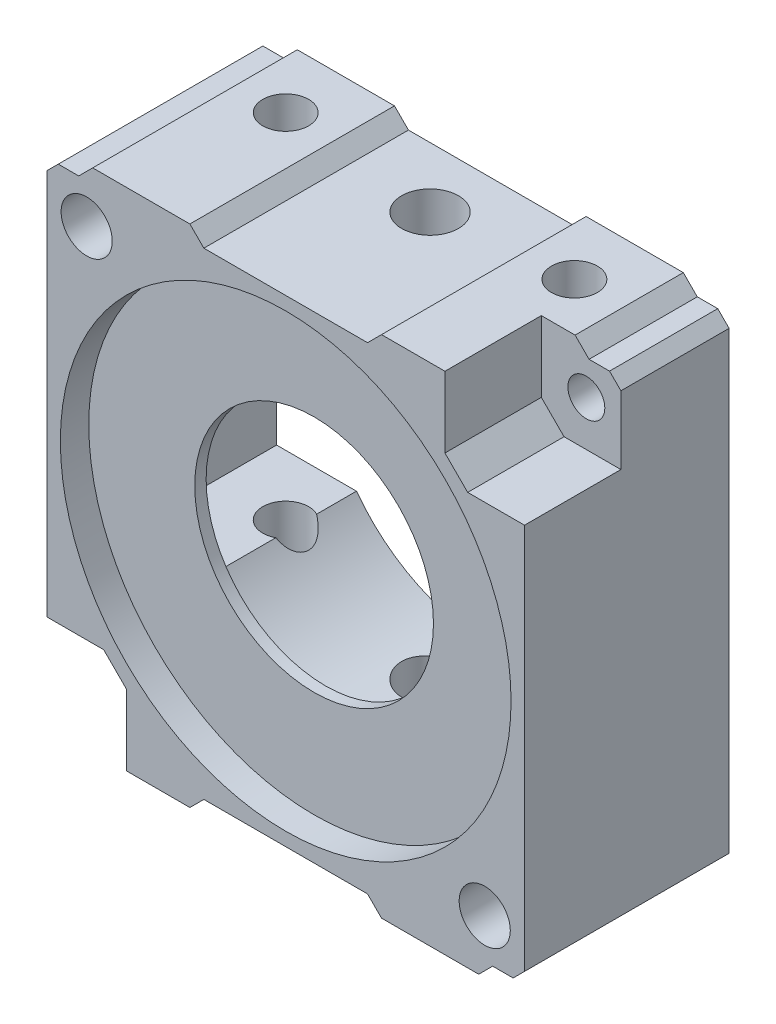
from build123d import *

# Parameters (mm, degrees)
BOSS_EXTRUDE2_DEPTH     = 18
SKETCH2_R               = 19.825
CUT_EXTRUDE1_DEPTH      = 2.5
SKETCH3_R               = 14.7
CUT_EXTRUDE2_DEPTH      = 14.5
CUT_EXTRUDE3_DEPTH      = 14.5
SKETCH5_R               = 10.5
CUT_EXTRUDE4_DEPTH      = 14.5
SKETCH7_R               = 2.5
SKETCH7_R_2             = 2.02
CUT_EXTRUDE6_DEPTH      = 30
CUT_EXTRUDE6_DEPTH_BACK = 60
SKETCH9_R               = 1.623885446
SKETCH9_R_2             = 2.25
CUT_EXTRUDE7_DEPTH      = 30
CUT_EXTRUDE8_DEPTH      = 8.48


with BuildPart() as part:
    # Sketch1 → Boss-Extrude2 (new body)
    with BuildSketch(Plane.XY):
        Polygon((-7.2, 21), (7.2, 21), (8.43, 22.23), (16.98, 22.23), (18.21, 21), (20.01, 21), (21.01, 20), (21.01, -20), (20.01, -21), (18.21, -21), (16.98, -22.23), (8.43, -22.23), (7.2, -21), (-7.2, -21), (-8.43, -22.23), (-16.98, -22.23), (-18.21, -21), (-20.01, -21), (-21.01, -20), (-21.01, 20), (-20.01, 21), (-18.21, 21), (-16.98, 22.23), (-8.43, 22.23), align=None)
    extrude(amount=BOSS_EXTRUDE2_DEPTH)

    # Sketch2 → Cut-Extrude1 (cut)
    with BuildSketch(Plane.XY.offset(18)):
        Circle(SKETCH2_R)
    extrude(amount=-CUT_EXTRUDE1_DEPTH, mode=Mode.SUBTRACT)

    # Sketch3 → Cut-Extrude2 (cut)
    with BuildSketch(Plane(origin=(0, 0, 0), x_dir=(-1, 0, 0), z_dir=(0, 0, -1))):
        Circle(SKETCH3_R)
    extrude(amount=-CUT_EXTRUDE2_DEPTH, mode=Mode.SUBTRACT)

    # Sketch4 → Cut-Extrude3 (cut)
    with BuildSketch(Plane(origin=(0, 0, 0), x_dir=(-1, 0, 0), z_dir=(0, 0, -1))):
        Polygon((18.8, 0), (18.8, 8.8), (-18.8, 8.8), (-18.8, -8.8), (18.8, -8.8), align=None)
    extrude(amount=-CUT_EXTRUDE3_DEPTH, mode=Mode.SUBTRACT)

    # Sketch5 → Cut-Extrude4 (cut)
    with BuildSketch(Plane(origin=(0, 0, 14.5), x_dir=(-1, 0, 0), z_dir=(0, 0, -1))):
        Circle(SKETCH5_R)
    extrude(amount=-CUT_EXTRUDE4_DEPTH, mode=Mode.SUBTRACT)

    # Sketch7 → Cut-Extrude6 (cut, two sides)
    with BuildSketch(Plane(origin=(0, 21, 0), x_dir=(1, 0, 0), z_dir=(0, 1, 0))) as cut_extrude6_sk:
        with Locations((0, -5.3)):
            Circle(SKETCH7_R)
        with Locations((12.7, -5.3)):
            Circle(SKETCH7_R_2)
        with Locations((-12.7, -5.3)):
            Circle(SKETCH7_R_2)
    extrude(amount=CUT_EXTRUDE6_DEPTH, mode=Mode.SUBTRACT)
    extrude(cut_extrude6_sk.sketch, amount=-CUT_EXTRUDE6_DEPTH_BACK, mode=Mode.SUBTRACT)

    # Sketch9 → Cut-Extrude7 (cut)
    with BuildSketch(Plane.XY.offset(18)):
        with Locations((17.97, 17.97)):
            Circle(SKETCH9_R)
        with Locations((-17.51, 17.505)):
            Circle(SKETCH9_R_2)
        with Locations((17.51, -17.505)):
            Circle(SKETCH9_R_2)
        with Locations((-17.97, -17.97)):
            Circle(SKETCH9_R)
    extrude(amount=-CUT_EXTRUDE7_DEPTH, mode=Mode.SUBTRACT)

    # Sketch10 → Cut-Extrude8 (cut)
    with BuildSketch(Plane.XY.offset(18)):
        Polygon((14.01, 22.23), (14.01, 16), (16.01, 14), (21.01, 14), (21.01, 20), (20.01, 21), (18.21, 21), (16.98, 22.23), align=None)
        Polygon((-21.01, -14), (-16.01, -14), (-14.01, -16), (-14.01, -22.23), (-16.98, -22.23), (-18.21, -21), (-20.01, -21), (-21.01, -20), align=None)
    extrude(amount=-CUT_EXTRUDE8_DEPTH, mode=Mode.SUBTRACT)


solid = part.part
